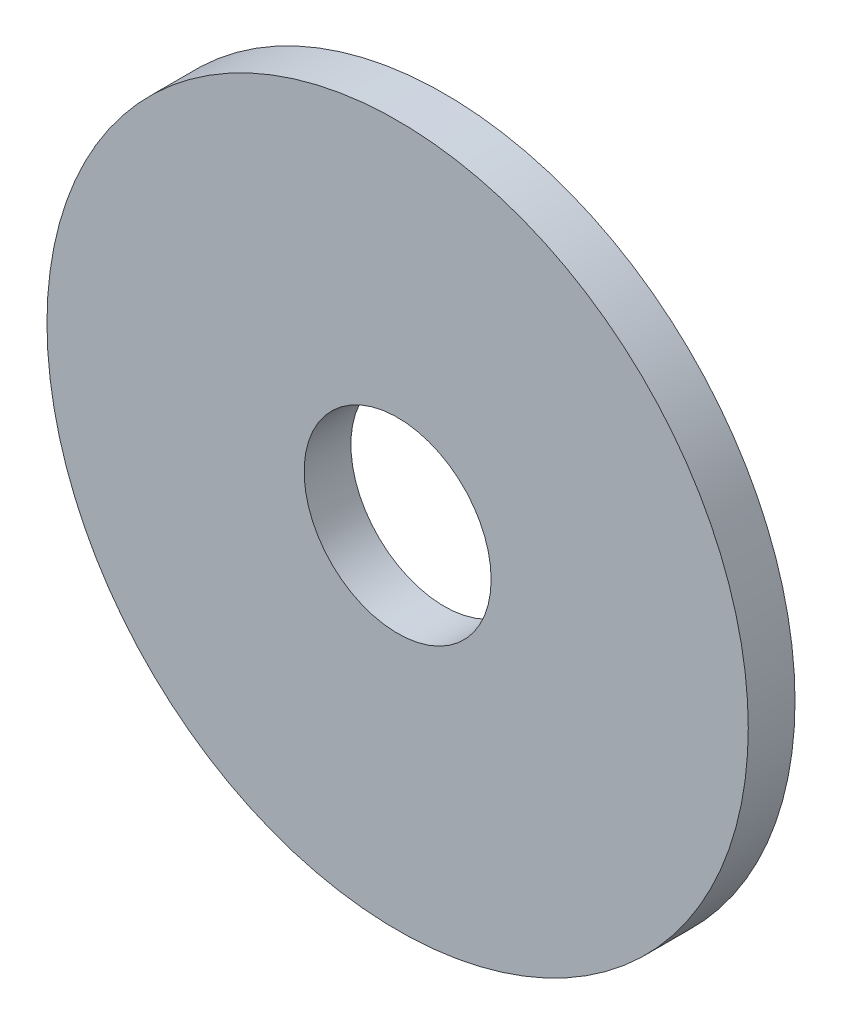
from build123d import *

# Parameters (mm, degrees)
ESQUISSE1_R          = 15
ESQUISSE1_R_2        = 4
BASE_EXTRUSION_DEPTH = 2


with BuildPart() as part:
    # Esquisse1 → Base-Extrusion (new body)
    with BuildSketch(Plane.XY):
        Circle(ESQUISSE1_R)
        Circle(ESQUISSE1_R_2, mode=Mode.SUBTRACT)
    extrude(amount=BASE_EXTRUSION_DEPTH)


solid = part.part
